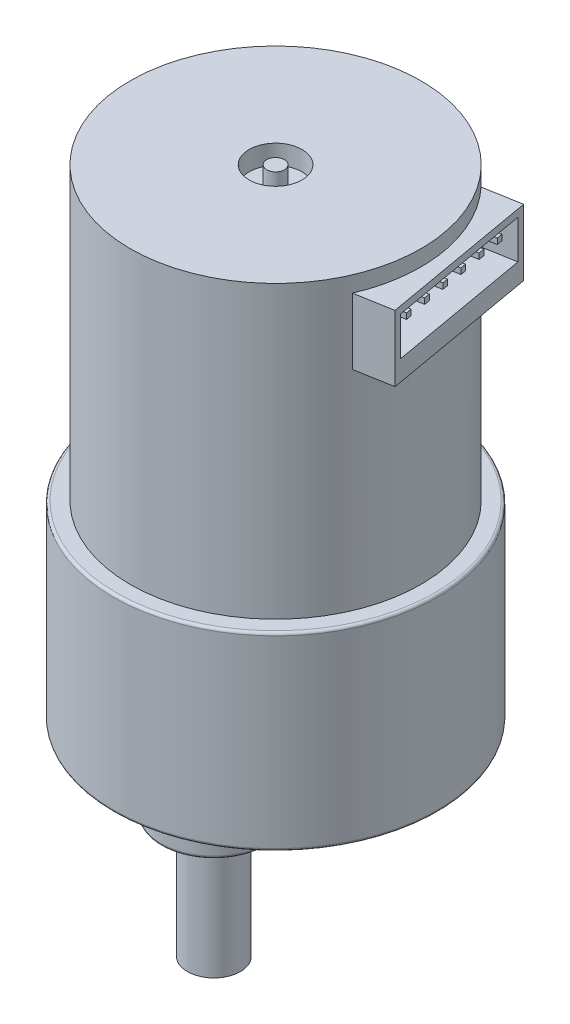
from build123d import *

# Parameters (mm, degrees)
SKETCH_1_R          = 18.4
EXTRUDE_1_DEPTH     = 21.5
SKETCH_2_R          = 6
EXTRUDE_2_DEPTH     = 6
SKETCH_3_R          = 3
EXTRUDE_3_DEPTH     = 13.8
SKETCH_4_W          = 8.972007795
SKETCH_4_H          = 2.543787651
CUT_EXTRUDE_1_DEPTH = 12
SKETCH_6_R          = 1.5
CUT_EXTRUDE_2_DEPTH = 6
CUT_EXTRUDE_3_DEPTH = 0.72
SKETCH_8_R          = 16.5
EXTRUDE_4_DEPTH     = 33
SKETCH_10_W         = 7.5
SKETCH_10_H         = 18
EXTRUDE_5_DEPTH     = 18
SKETCH_11_W         = 16.4
SKETCH_11_H         = 5.9
CUT_EXTRUDE_4_DEPTH = 5
SKETCH_12_W         = 0.64
SKETCH_12_H         = 0.64
EXTRUDE_6_DEPTH     = 4.5
SKETCH_13_W         = 16.4
SKETCH_13_H         = 1.5
EXTRUDE_7_DEPTH     = 5
SKETCH_14_R         = 3
CUT_EXTRUDE_5_DEPTH = 2.2
SKETCH_15_R         = 1
EXTRUDE_8_DEPTH     = 2.2
CHAMFER_1_SIZE      = 0.7
FILLET_1_R          = 0.3
FILLET_2_R          = 0.3


with BuildPart() as part:
    # 草图1 → 凸台-拉伸1 (new body)
    with BuildSketch(Plane(origin=(0, 0, 0), x_dir=(1, 0, 0), z_dir=(0, 1, 0))):
        Circle(SKETCH_1_R)
    extrude(amount=EXTRUDE_1_DEPTH)

    # 草图2 → 凸台-拉伸2 (add)
    with BuildSketch(Plane.XZ):
        with Locations((0, 7)):
            Circle(SKETCH_2_R)
    extrude(amount=EXTRUDE_2_DEPTH)

    # 草图3 → 凸台-拉伸3 (add)
    with BuildSketch(Plane.XZ.offset(6)):
        with Locations((0, 7)):
            Circle(SKETCH_3_R)
    extrude(amount=EXTRUDE_3_DEPTH)

    # 草图4 → 切除-拉伸1 (cut)
    with BuildSketch(Plane.XZ.offset(19.8)):
        with Locations((-0.051563263, 3.228106175)):
            Rectangle(SKETCH_4_W, SKETCH_4_H)
    extrude(amount=-CUT_EXTRUDE_1_DEPTH, mode=Mode.SUBTRACT)

    # 草图6 → 切除-拉伸2 (cut)
    with BuildSketch(Plane.XZ):
        with Locations((-15.5, 0)):
            Circle(SKETCH_6_R)
        with Locations((-7.75, 13.423393759)):
            Circle(SKETCH_6_R)
        with Locations((7.75, 13.423393759)):
            Circle(SKETCH_6_R)
        with Locations((15.5, 0)):
            Circle(SKETCH_6_R)
        with Locations((7.75, -13.423393759)):
            Circle(SKETCH_6_R)
        with Locations((-7.75, -13.423393759)):
            Circle(SKETCH_6_R)
    extrude(amount=-CUT_EXTRUDE_2_DEPTH, mode=Mode.SUBTRACT)

    # 草图7 → 切除-拉伸3 (cut)
    with BuildSketch(Plane.XZ):
        with BuildLine():
            ThreePointArc((-9.986582197, 7.517857143), (0, -12.5), (9.986582197, 7.517857143))
            ThreePointArc((9.986582197, 7.517857143), (0, -3), (-9.986582197, 7.517857143))
        make_face()
    extrude(amount=-CUT_EXTRUDE_3_DEPTH, mode=Mode.SUBTRACT)

    # 草图8 → 凸台-拉伸4 (add)
    with BuildSketch(Plane(origin=(0, 21.5, 0), x_dir=(1, 0, 0), z_dir=(0, 1, 0))):
        Circle(SKETCH_8_R)
    extrude(amount=EXTRUDE_4_DEPTH)

    # 草图10 → 凸台-拉伸5 (add)
    with BuildSketch(Plane(origin=(0, 0, 0), x_dir=(0, -1, 0), z_dir=(-0.984807753, 0, 0.173648178))):
        with Locations((-48.95, 0)):
            Rectangle(SKETCH_10_W, SKETCH_10_H)
    extrude(amount=-EXTRUDE_5_DEPTH)

    # 草图11 → 切除-拉伸4 (cut)
    with BuildSketch(Plane(origin=(17.726539554, 0, -3.125667198), x_dir=(-0.173648178, 0, -0.984807753), z_dir=(0.984807753, 0, -0.173648178))):
        with Locations((0, 48.95)):
            Rectangle(SKETCH_11_W, SKETCH_11_H)
    extrude(amount=-CUT_EXTRUDE_4_DEPTH, mode=Mode.SUBTRACT)

    # 草图12 → 凸台-拉伸6 (add)
    with BuildSketch(Plane(origin=(12.802500789, 0, -2.25742631), x_dir=(-0.173648178, 0, -0.984807753), z_dir=(0.984807753, 0, -0.173648178))):
        with Locations((-1.27, 50.58)):
            Rectangle(SKETCH_12_W, SKETCH_12_H)
        with Locations((1.27, 50.58)):
            Rectangle(SKETCH_12_W, SKETCH_12_H)
        with Locations((3.81, 50.58)):
            Rectangle(SKETCH_12_W, SKETCH_12_H)
        with Locations((6.35, 50.58)):
            Rectangle(SKETCH_12_W, SKETCH_12_H)
        with Locations((-6.35, 50.58)):
            Rectangle(SKETCH_12_W, SKETCH_12_H)
        with Locations((-3.81, 50.58)):
            Rectangle(SKETCH_12_W, SKETCH_12_H)
    extrude(amount=EXTRUDE_6_DEPTH)

    # 草图13 → 凸台-拉伸7 (add)
    with BuildSketch(Plane(origin=(12.802500789, 0, -2.25742631), x_dir=(-0.173648178, 0, -0.984807753), z_dir=(0.984807753, 0, -0.173648178))):
        with Locations((0, 46.75)):
            Rectangle(SKETCH_13_W, SKETCH_13_H)
    extrude(amount=EXTRUDE_7_DEPTH)

    # 草图14 → 切除-拉伸5 (cut)
    with BuildSketch(Plane(origin=(0, 54.5, 0), x_dir=(1, 0, 0), z_dir=(0, 1, 0))):
        Circle(SKETCH_14_R)
    extrude(amount=-CUT_EXTRUDE_5_DEPTH, mode=Mode.SUBTRACT)

    # 草图15 → 凸台-拉伸8 (add)
    with BuildSketch(Plane(origin=(0, 52.3, 0), x_dir=(1, 0, 0), z_dir=(0, 1, 0))):
        Circle(SKETCH_15_R)
    extrude(amount=EXTRUDE_8_DEPTH)

    # 倒角1
    chamfer_1_edges = [part.edges().sort_by_distance(p)[0] for p in [
        (0, 0, -12.5),
        (0, 0, -3),
    ]]
    chamfer(chamfer_1_edges, length=CHAMFER_1_SIZE)

    # 圆角1
    fillet_1_edges = [part.edges().sort_by_distance(p)[0] for p in [
        (-6, -6, 7),
    ]]
    fillet(fillet_1_edges, radius=FILLET_1_R)

    # 圆角2
    fillet_2_edges = [part.edges().sort_by_distance(p)[0] for p in [
        (-18.4, 0, 0),
        (-18.4, 21.5, 0),
    ]]
    fillet(fillet_2_edges, radius=FILLET_2_R)


solid = part.part
